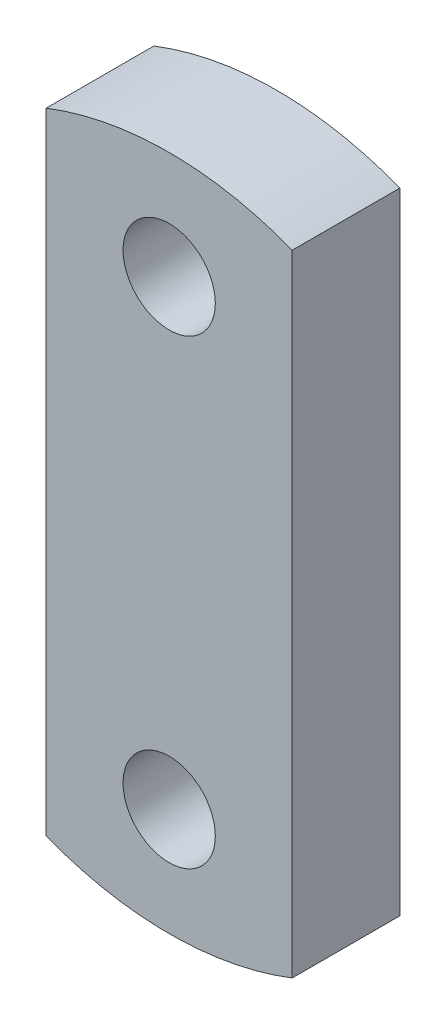
from build123d import *

# Parameters (mm, degrees)
SKETCH1_R           = 15
BOSS_EXTRUDE1_DEPTH = 35


with BuildPart() as part:
    # Sketch1 → Boss-Extrude1 (new body)
    with BuildSketch(Plane.XY):
        with BuildLine():
            Line((-40, 102.46950766), (-40, -102.46950766))
            ThreePointArc((-40, -102.46950766), (0, -110), (40, -102.46950766))
            Line((40, -102.46950766), (40, 102.46950766))
            ThreePointArc((40, 102.46950766), (0, 110), (-40, 102.46950766))
        make_face()
        with Locations((0, 75)):
            Circle(SKETCH1_R, mode=Mode.SUBTRACT)
        with Locations((0, -75)):
            Circle(SKETCH1_R, mode=Mode.SUBTRACT)
    extrude(amount=BOSS_EXTRUDE1_DEPTH)


solid = part.part
